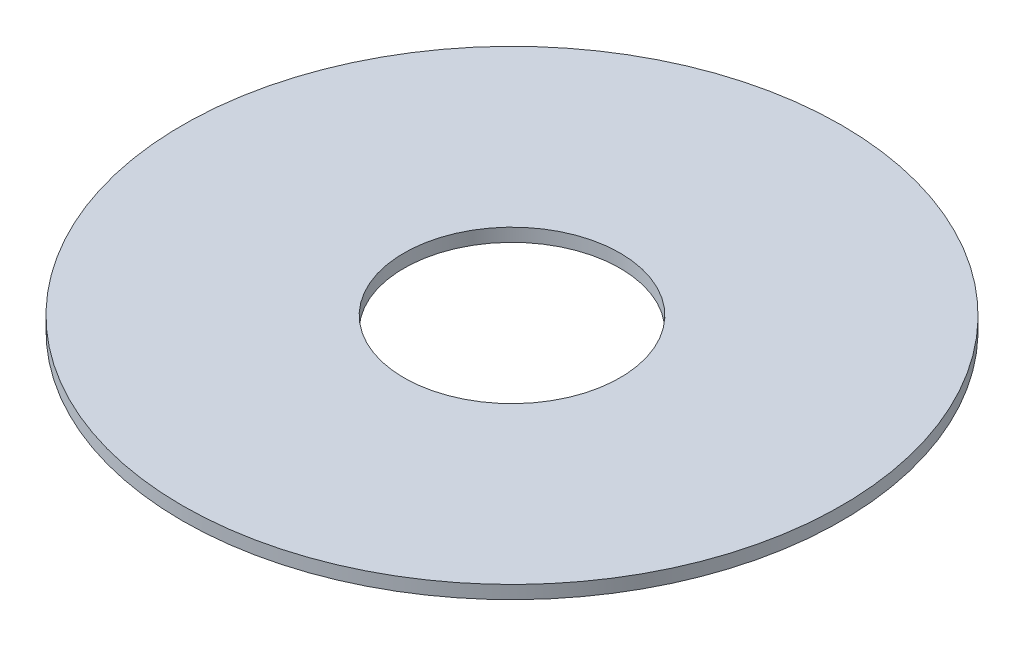
from build123d import *

# Parameters (mm, degrees)
SKETCH1_R           = 63.5
SKETCH1_R_2         = 20.828
BOSS_EXTRUDE1_DEPTH = 2.54


with BuildPart() as part:
    # Sketch1 → Boss-Extrude1 (new body)
    with BuildSketch(Plane(origin=(0, 0, 0), x_dir=(1, 0, 0), z_dir=(0, 1, 0))):
        Circle(SKETCH1_R)
        Circle(SKETCH1_R_2, mode=Mode.SUBTRACT)
    extrude(amount=BOSS_EXTRUDE1_DEPTH)


solid = part.part
